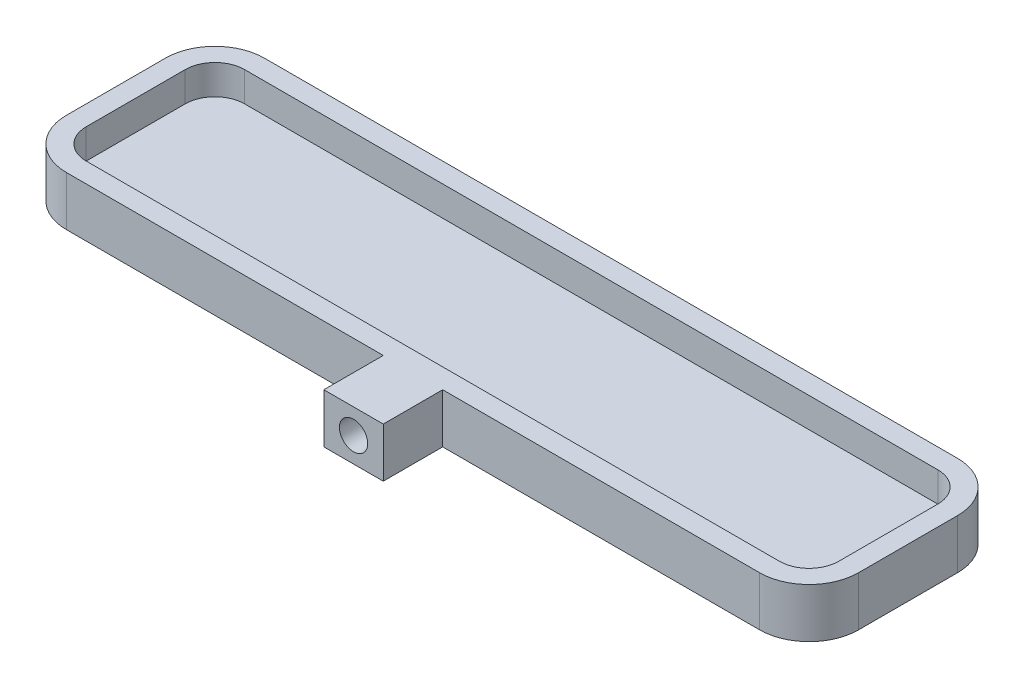
from build123d import *

# Parameters (mm, degrees)
SKETCH1_W           = 80
SKETCH1_H           = 20
BOSS_EXTRUDE1_DEPTH = 5
FILLET1_R           = 5
SHELL1_T            = -2
SKETCH3_W           = 6
SKETCH3_H           = 5
BOSS_EXTRUDE2_DEPTH = 6
SKETCH5_R           = 1.425
CUT_EXTRUDE1_DEPTH  = 4


with BuildPart() as part:
    # Sketch1 → Boss-Extrude1 (new body)
    with BuildSketch(Plane(origin=(0, 0, 0), x_dir=(1, 0, 0), z_dir=(0, 1, 0))):
        Rectangle(SKETCH1_W, SKETCH1_H)
    extrude(amount=BOSS_EXTRUDE1_DEPTH)

    # Fillet1
    fillet1_edges = [part.edges().sort_by_distance(p)[0] for p in [
        (-40, 2.5, -10),
        (40, 2.5, -10),
        (40, 2.5, 10),
        (-40, 2.5, 10),
    ]]
    fillet(fillet1_edges, radius=FILLET1_R)

    # Shell1
    shell1_openings = [part.faces().sort_by_distance(p)[0] for p in [
        (0, 5, 0),
    ]]
    offset(amount=SHELL1_T, openings=shell1_openings, kind=Kind.INTERSECTION)

    # Sketch3 → Boss-Extrude2 (add)
    with BuildSketch(Plane.XY.offset(10)):
        with Locations((0, 2.5)):
            Rectangle(SKETCH3_W, SKETCH3_H)
    extrude(amount=BOSS_EXTRUDE2_DEPTH)

    # Sketch5 → Cut-Extrude1 (cut)
    with BuildSketch(Plane.XY.offset(16)):
        with Locations((0, 2.5)):
            Circle(SKETCH5_R)
    extrude(amount=-CUT_EXTRUDE1_DEPTH, mode=Mode.SUBTRACT)


solid = part.part
